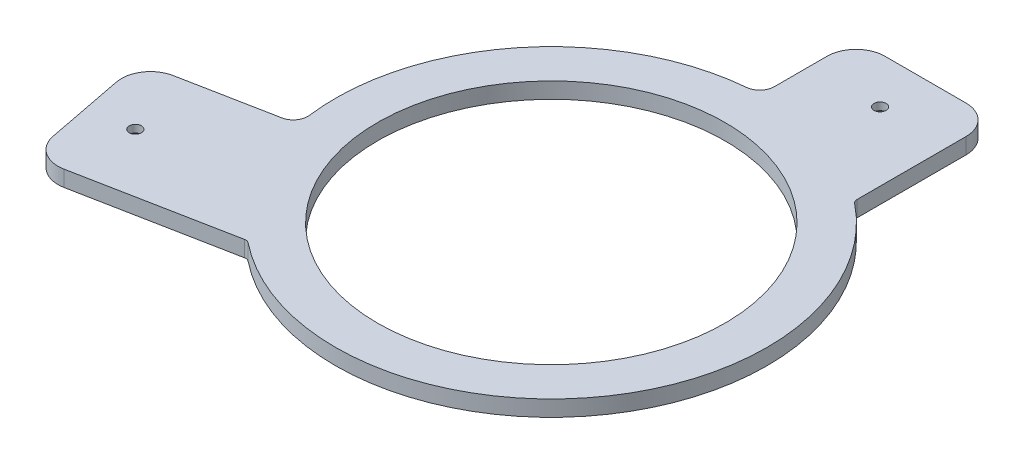
from build123d import *

# Parameters (mm, degrees)
SKETCH1_R                     = 60
BOSS_EXTRUDE1_DEPTH           = 5.5
FILLET1_R                     = 2
FILLET2_R                     = 10
FILLET3_R                     = 5
FILLET4_R                     = 2.15
CSK_FOR_M4_SFHCS1_D           = 4.2
CSK_FOR_M4_SFHCS1_CSINK_D     = 10
CSK_FOR_M4_SFHCS1_CSINK_ANGLE = 90


with BuildPart() as part:
    # Sketch1 → Boss-Extrude1 (new body)
    with BuildSketch(Plane(origin=(0, 0, 0), x_dir=(1, 0, 0), z_dir=(0, 1, 0))):
        with BuildLine():
            Line((-119.071377352, -23.145131139), (-73.131225167, -14.215270156))
            ThreePointArc((-73.131225167, -14.215270156), (-58.179525881, 46.533780937), (-2.2, 74.467509694))
            Line((-2.2, 74.467509694), (-2.2, 107.4))
            Line((-2.2, 107.4), (45.8, 107.4))
            Line((45.8, 107.4), (45.8, 58.758914217))
            ThreePointArc((45.8, 58.758914217), (58.254488227, -46.439903116), (-47.074251085, -57.743093828))
            Line((-47.074251085, -57.743093828), (-109.969788273, -69.96874779))
            Line((-109.969788273, -69.96874779), (-119.071377352, -23.145131139))
        make_face()
        Circle(SKETCH1_R, mode=Mode.SUBTRACT)
    extrude(amount=BOSS_EXTRUDE1_DEPTH)

    # Fillet1
    fillet1_edges = [part.edges().sort_by_distance(p)[0] for p in [
        (-47.074251085, 2.75, 57.743093828),
    ]]
    fillet(fillet1_edges, radius=FILLET1_R)

    # Fillet2
    fillet2_edges = [part.edges().sort_by_distance(p)[0] for p in [
        (-119.071377352, 2.75, 23.145131139),
        (-2.2, 2.75, -107.4),
        (45.8, 2.75, -107.4),
        (-109.969788273, 2.75, 69.96874779),
    ]]
    fillet(fillet2_edges, radius=FILLET2_R)

    # Fillet3
    fillet3_edges = [part.edges().sort_by_distance(p)[0] for p in [
        (-73.131225167, 2.75, 14.215270156),
        (-2.2, 2.75, -74.467509694),
    ]]
    fillet(fillet3_edges, radius=FILLET3_R)

    # Fillet4
    fillet4_edges = [part.edges().sort_by_distance(p)[0] for p in [
        (45.8, 2.75, -58.758914217),
    ]]
    fillet(fillet4_edges, radius=FILLET4_R)

    # CSK for M4 SFHCS1 (through all)
    with Locations(Plane(origin=(0, 0, 0), x_dir=(-1, 0, 0), z_dir=(0, -1, 0))):
        with Locations((-22.1, 91.4), (99.767553711, -43.842048611)):
            CounterSinkHole(CSK_FOR_M4_SFHCS1_D / 2, CSK_FOR_M4_SFHCS1_CSINK_D / 2, counter_sink_angle=CSK_FOR_M4_SFHCS1_CSINK_ANGLE)


solid = part.part
